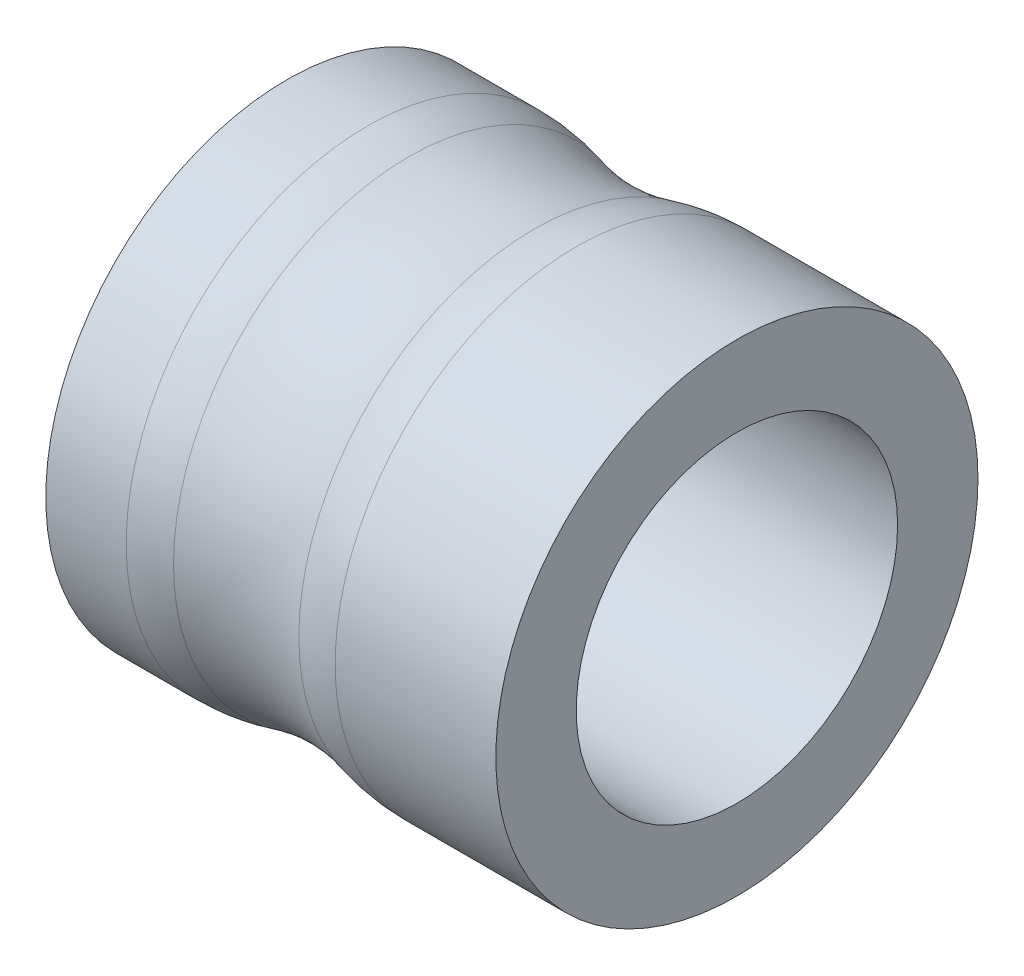
from build123d import *


with BuildPart() as part:
    # Sketch1 → Revolve1 (revolve)
    with BuildSketch(Plane.XY, mode=Mode.PRIVATE) as revolve1_sk:
        with BuildLine():
            Line((0, 2), (5.6, 2))
            Line((5.6, 2), (5.6, 3))
            Line((5.6, 3), (3.6, 3))
            ThreePointArc((3.6, 3), (3.337735311, 2.982729743), (3.08, 2.931217233))
            ThreePointArc((3.08, 2.931217233), (2.3, 2.828043082), (1.52, 2.931217233))
            ThreePointArc((1.52, 2.931217233), (1.262264689, 2.982729743), (1, 3))
            Line((1, 3), (0, 3))
            Line((0, 3), (0, 2))
        make_face()
    revolve(revolve1_sk.sketch.rotate(Axis((5.88, 0, 0), (-1, 0, 0)), 90), axis=Axis((5.88, 0, 0), (-1, 0, 0)))  # turned: the seam where the file's is


solid = part.part
